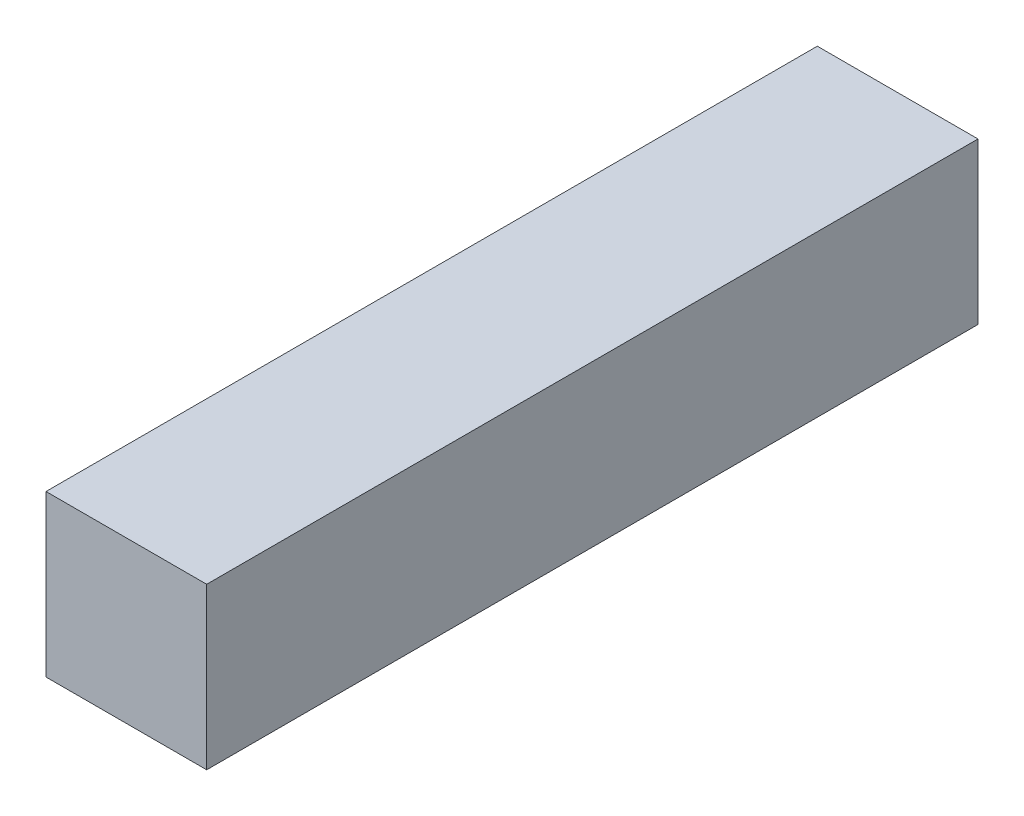
from build123d import *

# Parameters (mm, degrees)
SKETCH2_W           = 63.5
SKETCH2_H           = 63.5
BOSS_EXTRUDE1_DEPTH = 304.8


with BuildPart() as part:
    # Sketch2 → Boss-Extrude1 (new body)
    with BuildSketch(Plane.XY):
        with Locations((-29.765625, -8.9296875)):
            Rectangle(SKETCH2_W, SKETCH2_H)
    extrude(amount=BOSS_EXTRUDE1_DEPTH)


solid = part.part
